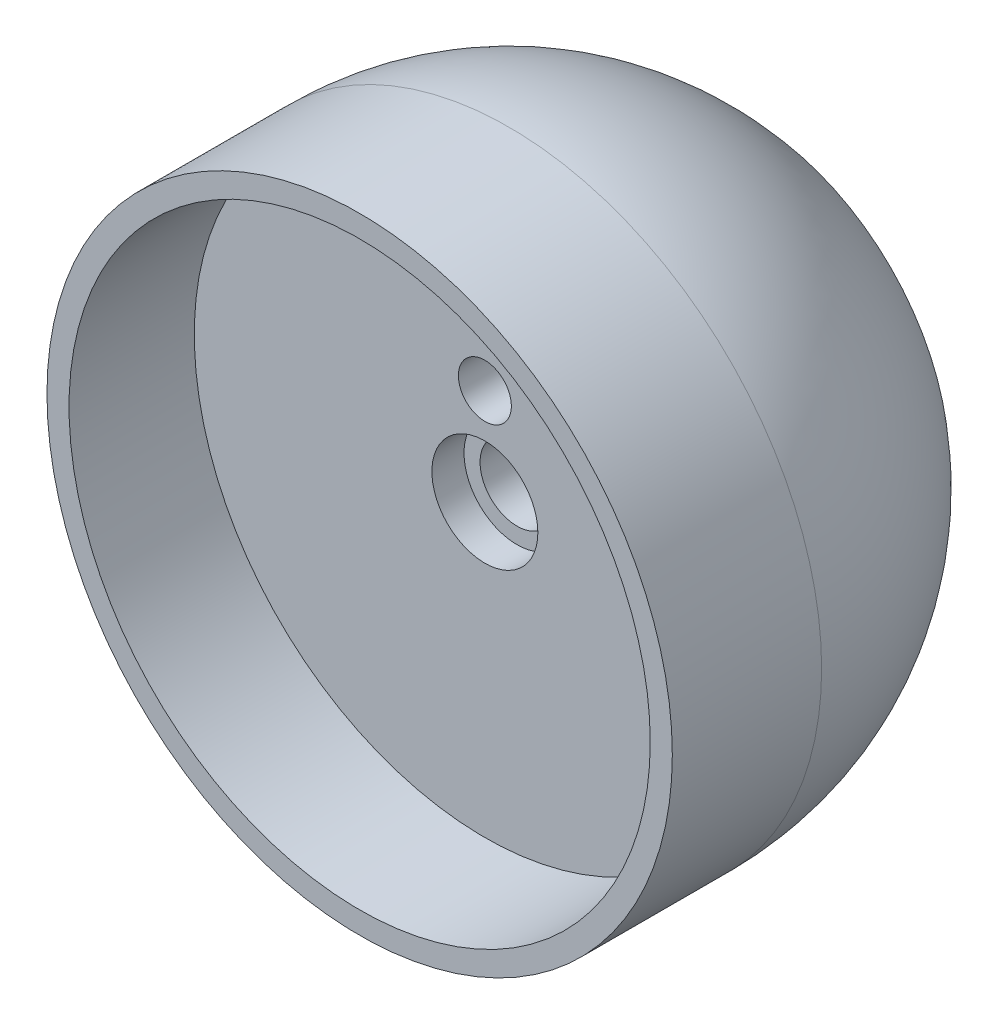
from build123d import *

# Parameters (mm, degrees)
SKETCH1_R               = 49.4665
BOSS_EXTRUDE1_DEPTH     = 23.622
SKETCH2_R               = 45.974
CUT_EXTRUDE2_DEPTH      = 19.812
SKETCH4_W               = 76.2
SKETCH4_H               = 76.2
CUT_EXTRUDE3_DEPTH      = 50.4665
CUT_EXTRUDE3_DEPTH_BACK = 50.4665
SKETCH5_R               = 8.382
CUT_EXTRUDE4_DEPTH      = 5.08
SKETCH6_R               = 5.842
CUT_EXTRUDE5_DEPTH      = 37.83
SKETCH7_R               = 4.191
CUT_EXTRUDE6_DEPTH      = 42.91


with BuildPart() as part:
    # Sketch1 → Boss-Extrude1 (new body)
    with BuildSketch(Plane.XY):
        Circle(SKETCH1_R)
    extrude(amount=BOSS_EXTRUDE1_DEPTH)

    # Sketch2 → Cut-Extrude2 (cut)
    with BuildSketch(Plane.XY.offset(23.622)):
        Circle(SKETCH2_R)
    extrude(amount=-CUT_EXTRUDE2_DEPTH, mode=Mode.SUBTRACT)

    # Sketch3 → Revolve1 (revolve)
    with BuildSketch(Plane(origin=(0, 0, 0), x_dir=(1, 0, 0), z_dir=(0, 1, 0))):
        with BuildLine():
            Line((0, 0), (-49.4665, 0))
            ThreePointArc((-49.4665, 0), (-34.978097592, 34.978097592), (0, 49.4665))
            Line((0, 49.4665), (0, 0))
        make_face()
    revolve(axis=Axis((0, 0, 0), (0, 0, -1)))

    # Sketch4 → Cut-Extrude3 (cut, two sides)
    with BuildSketch(Plane(origin=(0, 0, 0), x_dir=(1, 0, 0), z_dir=(0, 1, 0))) as cut_extrude3_sk:
        with Locations((6.55123422, 76.2)):
            Rectangle(SKETCH4_W, SKETCH4_H)
    extrude(amount=CUT_EXTRUDE3_DEPTH, mode=Mode.SUBTRACT)
    extrude(cut_extrude3_sk.sketch, amount=-CUT_EXTRUDE3_DEPTH_BACK, mode=Mode.SUBTRACT)

    # Sketch5 → Cut-Extrude4 (cut)
    with BuildSketch(Plane.XY.offset(3.81)):
        Circle(SKETCH5_R)
    cut_extrude4 = extrude(amount=-CUT_EXTRUDE4_DEPTH, mode=Mode.SUBTRACT)

    # Sketch6 → Cut-Extrude5 (cut, through all)
    with BuildSketch(Plane.XY.offset(-1.27)):
        Circle(SKETCH6_R)
    extrude(amount=-CUT_EXTRUDE5_DEPTH, mode=Mode.SUBTRACT)

    # Sketch7 → Cut-Extrude6 (cut, through all)
    with BuildSketch(Plane.XY.offset(3.81)):
        with Locations((0, 15.24)):
            Circle(SKETCH7_R)
    extrude(amount=-CUT_EXTRUDE6_DEPTH, mode=Mode.SUBTRACT)

    # Mirror1: Cut-Extrude4 across plane
    add(cut_extrude4.mirror(Plane.XY.offset(-17.145)), mode=Mode.SUBTRACT)


solid = part.part
